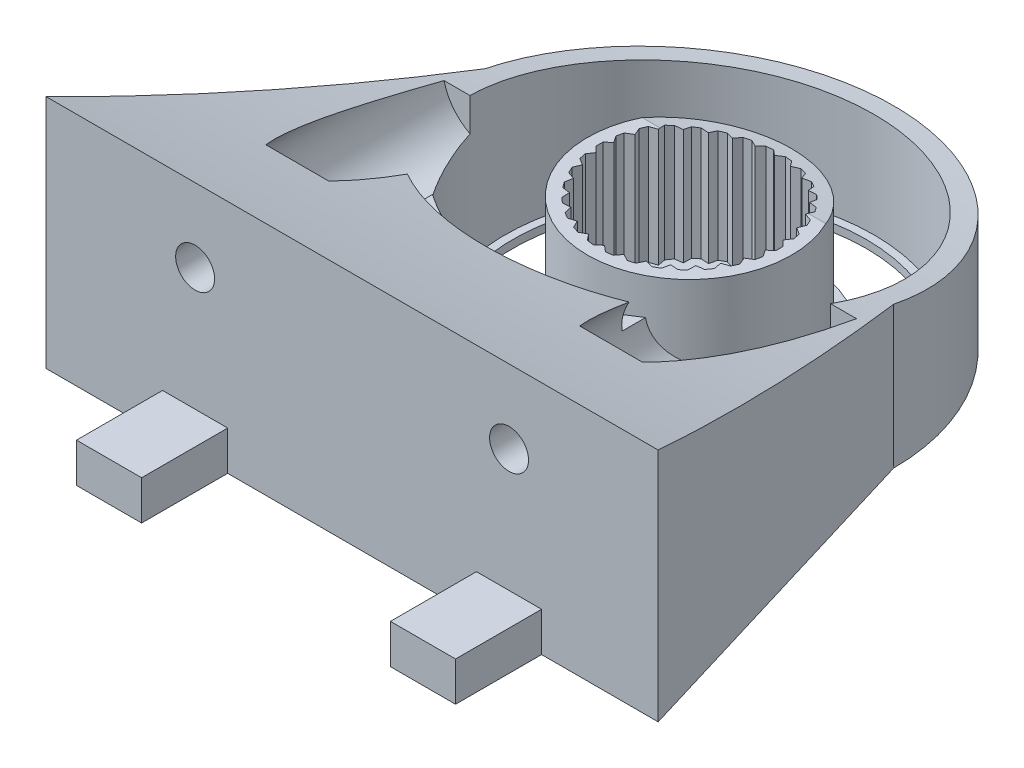
from build123d import *

# Parameters (mm, degrees)
BOSS_EXTRUDE5_DEPTH     = 5
SKETCH1_R               = 13
BOSS_EXTRUDE6_DEPTH     = 17
SKETCH3_R               = 15
BOSS_EXTRUDE7_DEPTH     = 2
SKETCH4_R               = 26
SKETCH4_R_2             = 23.5
BOSS_EXTRUDE8_DEPTH     = 20
BOSS_EXTRUDE12_DEPTH    = 25
SKETCH13_R              = 2.481116798
CUT_EXTRUDE3_DEPTH      = 15
SKETCH15_R              = 6.451275998
CUT_EXTRUDE4_DEPTH      = 2
CUT_EXTRUDE4_DEPTH_BACK = 23
SKETCH18_R              = 23.5
SKETCH18_R_2            = 22.5
BOSS_EXTRUDE13_DEPTH    = 1
CUT_EXTRUDE5_DEPTH      = 55.5


with BuildPart() as part:
    # Sketch2 → Boss-Extrude5 (new body)
    with BuildSketch(Plane(origin=(0, 0, 0), x_dir=(1, 0, 0), z_dir=(0, 1, 0))):
        with BuildLine():
            Line((24.15, 27.118189547), (39, 27.118189547))
            Line((39, 27.118189547), (26, 70.118189547))
            ThreePointArc((26, 70.118189547), (0, 44.118189547), (-26, 70.118189547))
            Line((-26, 70.118189547), (-39, 27.118189547))
            Line((-39, 27.118189547), (-24.15, 27.118189547))
            Line((-24.15, 27.118189547), (-24.15, 21.784598434))
            Line((-24.15, 21.784598434), (-24.15, 16.151251291))
            Line((-24.15, 16.151251291), (-15.85, 16.151251291))
            Line((-15.85, 16.151251291), (-15.85, 21.784598434))
            Line((-15.85, 21.784598434), (-15.85, 27.118189547))
            Line((-15.85, 27.118189547), (15.85, 27.118189547))
            Line((15.85, 27.118189547), (15.85, 21.784598434))
            Line((15.85, 21.784598434), (15.85, 16.151251291))
            Line((15.85, 16.151251291), (24.15, 16.151251291))
            Line((24.15, 16.151251291), (24.15, 21.784598434))
            Line((24.15, 21.784598434), (24.15, 27.118189547))
        make_face()
    extrude(amount=BOSS_EXTRUDE5_DEPTH)

    # Sketch4 → Boss-Extrude8 (add)
    with BuildSketch(Plane.XZ):
        with Locations((0, -70.118189547)):
            Circle(SKETCH4_R)
        with Locations((0, -70.118189547)):
            Circle(SKETCH4_R_2, mode=Mode.SUBTRACT)
    extrude(amount=-BOSS_EXTRUDE8_DEPTH)

    # Sketch12 → Boss-Extrude12 (add)
    with BuildSketch(Plane(origin=(0, 5, 0), x_dir=(1, 0, 0), z_dir=(0, 1, 0))):
        with BuildLine():
            Line((-24.15, 27.118189547), (-15.85, 27.118189547))
            Line((-15.85, 27.118189547), (15.85, 27.118189547))
            Line((15.85, 27.118189547), (24.15, 27.118189547))
            Line((24.15, 27.118189547), (39, 27.118189547))
            Line((39, 27.118189547), (26, 70.118189547))
            ThreePointArc((26, 70.118189547), (0, 44.118189547), (-26, 70.118189547))
            Line((-26, 70.118189547), (-39, 27.118189547))
            Line((-39, 27.118189547), (-24.15, 27.118189547))
        make_face()
    extrude(amount=BOSS_EXTRUDE12_DEPTH)

    # Sketch13 → Cut-Extrude3 (cut)
    with BuildSketch(Plane.XY.offset(-27.118189547)):
        with Locations((20, 20.625415109)):
            Circle(SKETCH13_R)
        with Locations((-20, 20.625415109)):
            Circle(SKETCH13_R)
    extrude(amount=-CUT_EXTRUDE3_DEPTH, mode=Mode.SUBTRACT)

    # Sketch15 → Cut-Extrude4 (cut, two sides)
    with BuildSketch(Plane.XY.offset(-42.118189547)) as cut_extrude4_sk:
        with Locations((-20, 20.625415109)):
            Circle(SKETCH15_R)
        with Locations((20, 20.625415109)):
            Circle(SKETCH15_R)
    extrude(amount=CUT_EXTRUDE4_DEPTH, mode=Mode.SUBTRACT)
    extrude(cut_extrude4_sk.sketch, amount=-CUT_EXTRUDE4_DEPTH_BACK, mode=Mode.SUBTRACT)

    # Sketch18 → Boss-Extrude13 (add)
    with BuildSketch(Plane.XZ):
        with Locations((0, -70.118189547)):
            Circle(SKETCH18_R)
        with Locations((0, -70.118189547)):
            Circle(SKETCH18_R_2, mode=Mode.SUBTRACT)
    extrude(amount=-BOSS_EXTRUDE13_DEPTH)


with BuildPart() as body_2:
    # Sketch1 → Boss-Extrude6 (new body)
    with BuildSketch(Plane(origin=(0, 0, 0), x_dir=(1, 0, 0), z_dir=(0, 1, 0))):
        with Locations((0, 70.118189547)):
            Circle(SKETCH1_R)
        with BuildLine():
            Line((0, 80.950012772), (-0.758068466, 81.593176789))
            ThreePointArc((-0.758068466, 81.593176789), (-1.202077328, 81.555191344), (-1.644281148, 81.500032082))
            Line((-1.644281148, 81.500032082), (-2.252062681, 80.713311446))
            Line((-2.252062681, 80.713311446), (-3.127286851, 81.184809489))
            ThreePointArc((-3.127286851, 81.184809489), (-3.553695435, 81.055339484), (-3.974767786, 80.909446241))
            Line((-3.974767786, 80.909446241), (-4.405699417, 80.013552452))
            Line((-4.405699417, 80.013552452), (-5.359827794, 80.292777795))
            ThreePointArc((-5.359827794, 80.292777795), (-5.75, 80.07748169), (-6.131537999, 79.8472307))
            Line((-6.131537999, 79.8472307), (-6.366785947, 78.881318616))
            Line((-6.366785947, 78.881318616), (-7.358118543, 78.956067771))
            ThreePointArc((-7.358118543, 78.956067771), (-7.695001973, 78.66435504), (-8.020330579, 78.359809376))
            Line((-8.020330579, 78.359809376), (-8.04961338, 77.36609399))
            Line((-8.04961338, 77.36609399), (-9.034824204, 77.23310006))
            ThreePointArc((-9.034824204, 77.23310006), (-9.303695435, 76.877719948), (-9.558596226, 76.512189717))
            Line((-9.558596226, 76.512189717), (-9.380634083, 75.53410116))
            Line((-9.380634083, 75.53410116), (-10.316664693, 75.199176618))
            ThreePointArc((-10.316664693, 75.199176618), (-10.505772763, 74.795660942), (-10.679105352, 74.385121569))
            Line((-10.679105352, 74.385121569), (-10.301676062, 73.465407004))
            Line((-10.301676062, 73.465407004), (-11.14761743, 72.94318966))
            ThreePointArc((-11.14761743, 72.94318966), (-11.248697408, 72.509173991), (-11.332886329, 72.071568017))
            Line((-11.332886329, 72.071568017), (-10.772485364, 71.250423383))
            Line((-10.772485364, 71.250423383), (-11.491365793, 70.563736641))
            ThreePointArc((-11.491365793, 70.563736641), (-11.5, 70.118189547), (-11.491365793, 69.672642452))
            Line((-11.491365793, 69.672642452), (-10.772485364, 68.985955711))
            Line((-10.772485364, 68.985955711), (-11.332886329, 68.164811076))
            ThreePointArc((-11.332886329, 68.164811076), (-11.248697408, 67.727205102), (-11.14761743, 67.293189433))
            Line((-11.14761743, 67.293189433), (-10.301676062, 66.77097209))
            Line((-10.301676062, 66.77097209), (-10.679105352, 65.851257524))
            ThreePointArc((-10.679105352, 65.851257524), (-10.505772763, 65.440718151), (-10.316664693, 65.037202475))
            Line((-10.316664693, 65.037202475), (-9.380634083, 64.702277934))
            Line((-9.380634083, 64.702277934), (-9.558596226, 63.724189376))
            ThreePointArc((-9.558596226, 63.724189376), (-9.303695435, 63.358659145), (-9.034824204, 63.003279034))
            Line((-9.034824204, 63.003279034), (-8.04961338, 62.870285104))
            Line((-8.04961338, 62.870285104), (-8.020330579, 61.876569718))
            ThreePointArc((-8.020330579, 61.876569718), (-7.695001973, 61.572024054), (-7.358118543, 61.280311323))
            Line((-7.358118543, 61.280311323), (-6.366785947, 61.355060477))
            Line((-6.366785947, 61.355060477), (-6.131537999, 60.389148393))
            ThreePointArc((-6.131537999, 60.389148393), (-5.75, 60.158897403), (-5.359827794, 59.943601299))
            Line((-5.359827794, 59.943601299), (-4.405699417, 60.222826641))
            Line((-4.405699417, 60.222826641), (-3.974767786, 59.326932852))
            ThreePointArc((-3.974767786, 59.326932852), (-3.553695435, 59.181039609), (-3.127286851, 59.051569604))
            Line((-3.127286851, 59.051569604), (-2.252062681, 59.523067647))
            Line((-2.252062681, 59.523067647), (-1.644281148, 58.736347011))
            ThreePointArc((-1.644281148, 58.736347011), (-1.202077328, 58.68118775), (-0.758068466, 58.643202305))
            Line((-0.758068466, 58.643202305), (0, 59.286366321))
            Line((0, 59.286366321), (0.758068466, 58.643202305))
            ThreePointArc((0.758068466, 58.643202305), (1.202077328, 58.68118775), (1.644281148, 58.736347011))
            Line((1.644281148, 58.736347011), (2.252062681, 59.523067647))
            Line((2.252062681, 59.523067647), (3.127286851, 59.051569604))
            ThreePointArc((3.127286851, 59.051569604), (3.553695435, 59.181039609), (3.974767786, 59.326932852))
            Line((3.974767786, 59.326932852), (4.405699417, 60.222826641))
            Line((4.405699417, 60.222826641), (5.359827794, 59.943601299))
            ThreePointArc((5.359827794, 59.943601299), (5.75, 60.158897403), (6.131537999, 60.389148393))
            Line((6.131537999, 60.389148393), (6.366785947, 61.355060477))
            Line((6.366785947, 61.355060477), (7.358118543, 61.280311323))
            ThreePointArc((7.358118543, 61.280311323), (7.695001973, 61.572024054), (8.020330579, 61.876569718))
            Line((8.020330579, 61.876569718), (8.04961338, 62.870285104))
            Line((8.04961338, 62.870285104), (9.034824204, 63.003279034))
            ThreePointArc((9.034824204, 63.003279034), (9.303695435, 63.358659145), (9.558596226, 63.724189376))
            Line((9.558596226, 63.724189376), (9.380634083, 64.702277934))
            Line((9.380634083, 64.702277934), (10.316664693, 65.037202475))
            ThreePointArc((10.316664693, 65.037202475), (10.505772763, 65.440718151), (10.679105352, 65.851257524))
            Line((10.679105352, 65.851257524), (10.301676062, 66.77097209))
            Line((10.301676062, 66.77097209), (11.14761743, 67.293189433))
            ThreePointArc((11.14761743, 67.293189433), (11.248697408, 67.727205102), (11.332886329, 68.164811076))
            Line((11.332886329, 68.164811076), (10.772485364, 68.985955711))
            Line((10.772485364, 68.985955711), (11.491365793, 69.672642452))
            ThreePointArc((11.491365793, 69.672642452), (11.5, 70.118189547), (11.491365793, 70.563736641))
            Line((11.491365793, 70.563736641), (10.772485364, 71.250423383))
            Line((10.772485364, 71.250423383), (11.332886329, 72.071568017))
            ThreePointArc((11.332886329, 72.071568017), (11.248697408, 72.509173991), (11.14761743, 72.94318966))
            Line((11.14761743, 72.94318966), (10.301676062, 73.465407004))
            Line((10.301676062, 73.465407004), (10.679105352, 74.385121569))
            ThreePointArc((10.679105352, 74.385121569), (10.505772763, 74.795660942), (10.316664693, 75.199176618))
            Line((10.316664693, 75.199176618), (9.380634083, 75.53410116))
            Line((9.380634083, 75.53410116), (9.558596226, 76.512189717))
            ThreePointArc((9.558596226, 76.512189717), (9.303695435, 76.877719948), (9.034824204, 77.23310006))
            Line((9.034824204, 77.23310006), (8.04961338, 77.36609399))
            Line((8.04961338, 77.36609399), (8.020330579, 78.359809376))
            ThreePointArc((8.020330579, 78.359809376), (7.695001973, 78.66435504), (7.358118543, 78.956067771))
            Line((7.358118543, 78.956067771), (6.366785947, 78.881318616))
            Line((6.366785947, 78.881318616), (6.131537999, 79.8472307))
            ThreePointArc((6.131537999, 79.8472307), (5.75, 80.07748169), (5.359827794, 80.292777795))
            Line((5.359827794, 80.292777795), (4.405699417, 80.013552452))
            Line((4.405699417, 80.013552452), (3.974767786, 80.909446241))
            ThreePointArc((3.974767786, 80.909446241), (3.553695435, 81.055339484), (3.127286851, 81.184809489))
            Line((3.127286851, 81.184809489), (2.252062681, 80.713311446))
            Line((2.252062681, 80.713311446), (1.644281148, 81.500032082))
            ThreePointArc((1.644281148, 81.500032082), (1.202077328, 81.555191344), (0.758068466, 81.593176789))
            Line((0.758068466, 81.593176789), (0, 80.950012772))
        make_face(mode=Mode.SUBTRACT)
    extrude(amount=BOSS_EXTRUDE6_DEPTH)

    # Sketch3 → Boss-Extrude7 (add)
    with BuildSketch(Plane.XZ):
        with Locations((0, -70.118189547)):
            Circle(SKETCH3_R)
    extrude(amount=-BOSS_EXTRUDE7_DEPTH)


with BuildPart() as cut_extrude5_tool:
    # Sketch16 → Cut-Extrude5 (new body, symmetric)
    with BuildSketch(Plane(origin=(0, 0, 0), x_dir=(0, 0, -1), z_dir=(1, 0, 0))):
        with BuildLine():
            Line((27.118189547, 30), (96.118189547, 30))
            Line((96.118189547, 30), (96.118189547, 14))
            add(Edge.make_bspline(
                [(27.118189547, 30), (60.758915516, 18.028083755), (96.118189547, 14)],
                knots=[0, 0, 0, 1, 1, 1], degree=2))
        make_face()
    extrude(amount=CUT_EXTRUDE5_DEPTH, both=True)


with BuildPart() as part_1:
    add(part.part)

    # Cut-Extrude5: cut by cut_extrude5_tool
    add(cut_extrude5_tool.part, mode=Mode.SUBTRACT)


with BuildPart() as body_2_1:
    add(body_2.part)

    # Cut-Extrude5: cut by cut_extrude5_tool
    add(cut_extrude5_tool.part, mode=Mode.SUBTRACT)


solid = Compound([part_1.part, body_2_1.part])
